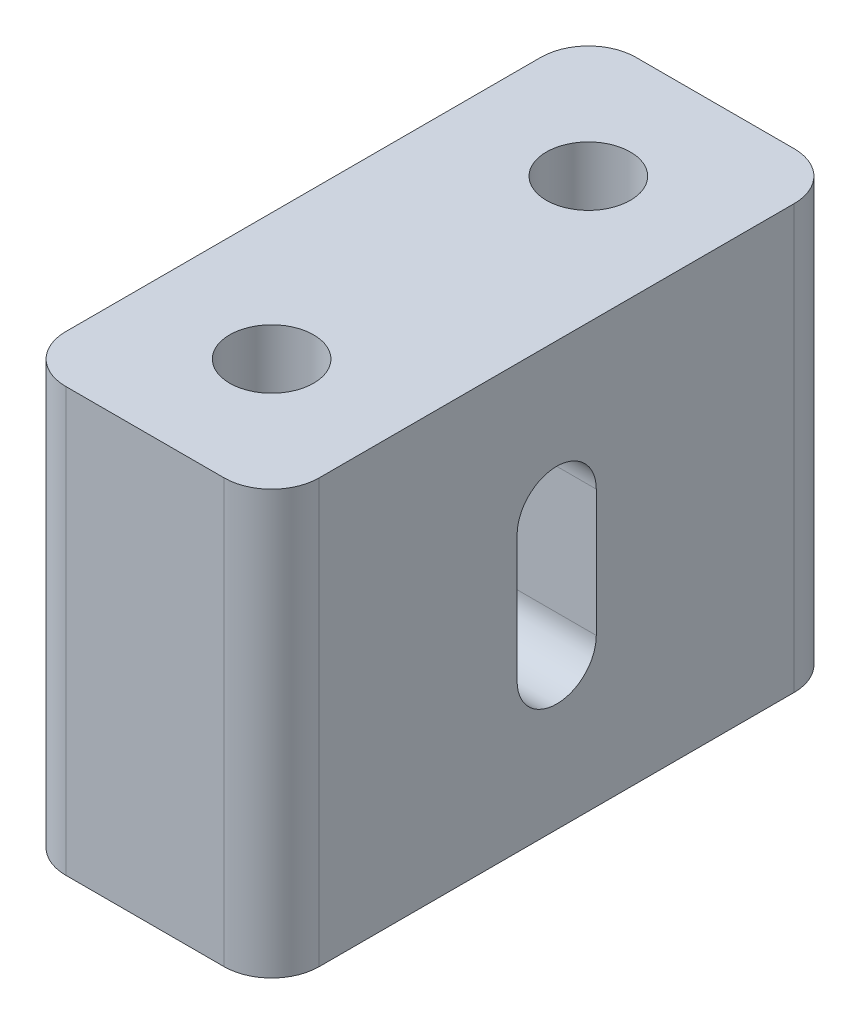
from build123d import *

# Parameters (mm, degrees)
SKETCH1_W               = 16
SKETCH1_H               = 36
BOSS_EXTRUDE1_DEPTH     = 13.366197724
M5_CLEARANCE_HOLE1_D    = 5.3
FILLET1_R               = 3
CUT_EXTRUDE1_DEPTH      = 9
CUT_EXTRUDE1_DEPTH_BACK = 9


with BuildPart() as part:
    # Sketch1 → Boss-Extrude1 (new body, symmetric)
    with BuildSketch(Plane(origin=(0, 0, 0), x_dir=(1, 0, 0), z_dir=(0, 1, 0))):
        Rectangle(SKETCH1_W, SKETCH1_H)
    extrude(amount=BOSS_EXTRUDE1_DEPTH, both=True)

    # M5 Clearance Hole1 (through all)
    with Locations(Plane(origin=(0, 13.366197724, 0), x_dir=(1, 0, 0), z_dir=(0, 1, 0))):
        with Locations((0, 10), (0, -10)):
            Hole(M5_CLEARANCE_HOLE1_D / 2)

    # Fillet1
    fillet1_edges = [part.edges().sort_by_distance(p)[0] for p in [
        (-8, 0, 18),
        (8, 0, 18),
        (8, 0, -18),
        (-8, 0, -18),
    ]]
    fillet(fillet1_edges, radius=FILLET1_R)

    # Sketch6 → Cut-Extrude1 (cut, two sides)
    with BuildSketch(Plane(origin=(0, 0, 0), x_dir=(0, 0, -1), z_dir=(1, 0, 0))) as cut_extrude1_sk:
        with BuildLine():
            Line((-2.5, -4), (-2.5, 4))
            ThreePointArc((-2.5, 4), (0, 6.5), (2.5, 4))
            Line((2.5, 4), (2.5, -4))
            ThreePointArc((2.5, -4), (0, -6.5), (-2.5, -4))
        make_face()
    extrude(amount=CUT_EXTRUDE1_DEPTH, mode=Mode.SUBTRACT)
    extrude(cut_extrude1_sk.sketch, amount=-CUT_EXTRUDE1_DEPTH_BACK, mode=Mode.SUBTRACT)


solid = part.part
